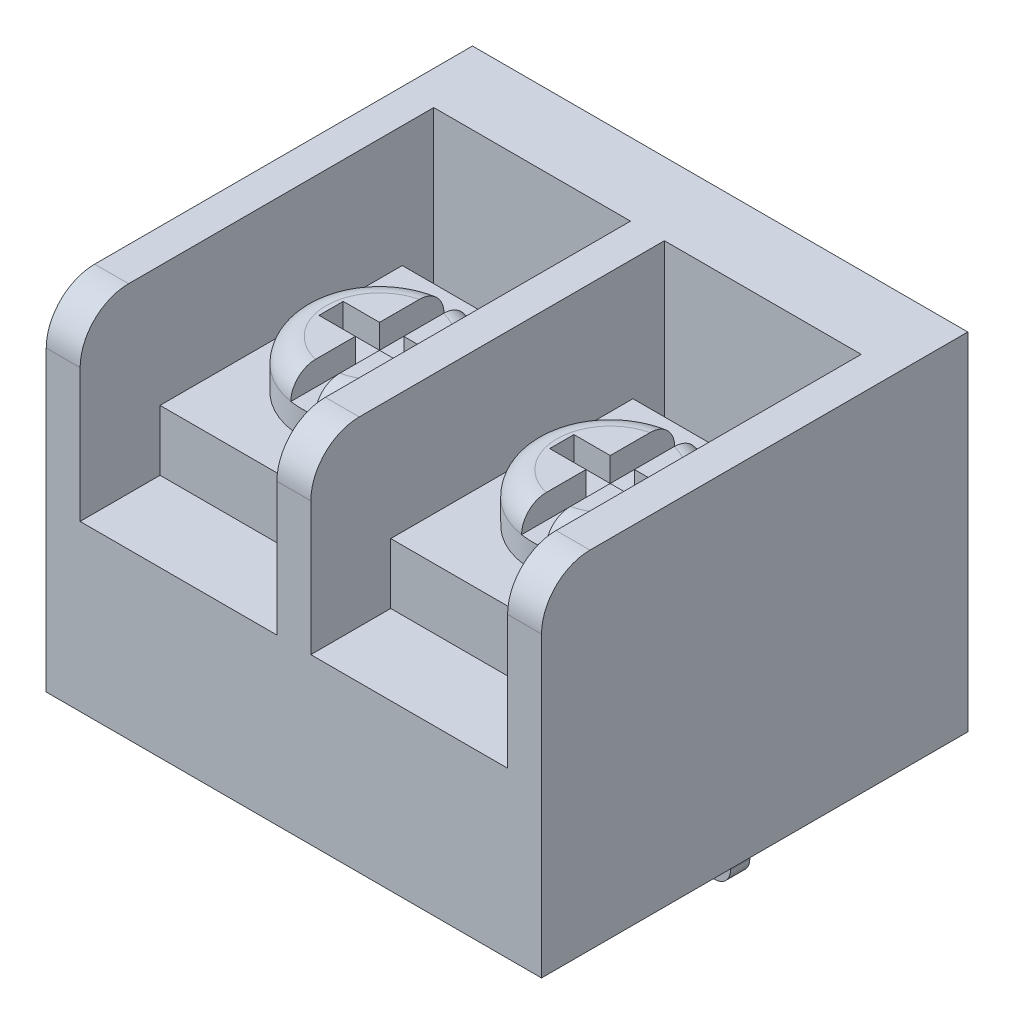
from build123d import *

# Parameters (mm, degrees)
SKETCH1_W             = 20.45
SKETCH1_H             = 17.6
BOSS_EXTRUDE1_DEPTH   = 14.3
FILLET1_R             = 2
SKETCH2_W             = 8.125
SKETCH2_H             = 14.6
CUT_EXTRUDE1_DEPTH    = 7.5
SKETCH3_W             = 1.35
SKETCH3_H             = 0.8
BOSS_EXTRUDE2_DEPTH   = 5.5
BOSS_EXTRUDE2_2_DEPTH = 5.5
FILLET3_R             = 0.65
FILLET4_R             = 0.65
SKETCH4_W             = 8.125
SKETCH4_H             = 10
BOSS_EXTRUDE3_DEPTH   = 2.5
BOSS_EXTRUDE3_2_DEPTH = 2.5
SKETCH5_R             = 3.2
BOSS_EXTRUDE4_DEPTH   = 2
CUT_EXTRUDE2_DEPTH    = 1
FILLET5_R             = 1
FILLET6_R             = 1


with BuildPart() as part:
    # Sketch1 → Boss-Extrude1 (new body)
    with BuildSketch(Plane(origin=(0, 0, 0), x_dir=(1, 0, 0), z_dir=(0, 1, 0))):
        Rectangle(SKETCH1_W, SKETCH1_H)
    extrude(amount=BOSS_EXTRUDE1_DEPTH)

    # Fillet1
    fillet1_edges = [part.edges().sort_by_distance(p)[0] for p in [
        (0, 14.3, 8.8),
    ]]
    fillet(fillet1_edges, radius=FILLET1_R)

    # Sketch2 → Cut-Extrude1 (cut)
    with BuildSketch(Plane(origin=(0, 14.3, 0), x_dir=(1, 0, 0), z_dir=(0, 1, 0))):
        with Locations((-4.7625, -1.5)):
            Rectangle(SKETCH2_W, SKETCH2_H)
        with Locations((4.7625, -1.5)):
            Rectangle(SKETCH2_W, SKETCH2_H)
    extrude(amount=-CUT_EXTRUDE1_DEPTH, mode=Mode.SUBTRACT)


with BuildPart() as body_2:
    # Sketch3 → Boss-Extrude2 (new body)
    with BuildSketch(Plane.XZ):
        with Locations((-4.75, -4.2)):
            Rectangle(SKETCH3_W, SKETCH3_H)
    extrude(amount=BOSS_EXTRUDE2_DEPTH)

    # Fillet4
    fillet4_edges = [body_2.edges().sort_by_distance(p)[0] for p in [
        (-4.075, -5.5, -4.2),
        (-5.425, -5.5, -4.2),
    ]]
    fillet(fillet4_edges, radius=FILLET4_R)


with BuildPart() as body_3:
    # Sketch3 → Boss-Extrude2 2 (new body)
    with BuildSketch(Plane.XZ):
        with Locations((4.75, -4.2)):
            Rectangle(SKETCH3_W, SKETCH3_H)
    extrude(amount=BOSS_EXTRUDE2_2_DEPTH)

    # Fillet3
    fillet3_edges = [body_3.edges().sort_by_distance(p)[0] for p in [
        (5.425, -5.5, -4.2),
        (4.075, -5.5, -4.2),
    ]]
    fillet(fillet3_edges, radius=FILLET3_R)


with BuildPart() as body_4:
    # Sketch4 → Boss-Extrude3 (new body)
    with BuildSketch(Plane(origin=(0, 6.8, 0), x_dir=(1, 0, 0), z_dir=(0, 1, 0))):
        with Locations((-4.7625, -0.5)):
            Rectangle(SKETCH4_W, SKETCH4_H)
    extrude(amount=BOSS_EXTRUDE3_DEPTH)



with BuildPart() as body_5:
    # Sketch4 → Boss-Extrude3 2 (new body)
    with BuildSketch(Plane(origin=(0, 6.8, 0), x_dir=(1, 0, 0), z_dir=(0, 1, 0))):
        with Locations((4.7625, -0.5)):
            Rectangle(SKETCH4_W, SKETCH4_H)
    extrude(amount=BOSS_EXTRUDE3_2_DEPTH)


with BuildPart() as body_4_1:
    add(body_4.part)

    add(body_5.part)  # Boss-Extrude4 merges body 5
    # Sketch5 → Boss-Extrude4 (add)
    with BuildSketch(Plane(origin=(0, 9.3, 0), x_dir=(1, 0, 0), z_dir=(0, 1, 0))):
        with Locations((-4.7625, -0.5)):
            Circle(SKETCH5_R)
        with Locations((4.7625, -0.5)):
            Circle(SKETCH5_R)
    extrude(amount=BOSS_EXTRUDE4_DEPTH)

    # Sketch6 → Cut-Extrude2 (cut)
    with BuildSketch(Plane(origin=(0, 11.3, 0), x_dir=(1, 0, 0), z_dir=(0, 1, 0))):
        Polygon((-5.2625, 2.7), (-5.2625, 0), (-6.7625, 0), (-6.7625, -1), (-5.2625, -1), (-5.2625, -3.7), (-4.2625, -3.7), (-4.2625, -1), (-2.7625, -1), (-2.7625, 0), (-4.2625, 0), (-4.2625, 2.7), align=None)
        Polygon((4.2625, 0), (4.2625, 2.7), (5.2625, 2.7), (5.2625, 0), (6.7625, 0), (6.7625, -1), (5.2625, -1), (5.2625, -3.7), (4.2625, -3.7), (4.2625, -1), (2.7625, -1), (2.7625, 0), align=None)
    extrude(amount=-CUT_EXTRUDE2_DEPTH, mode=Mode.SUBTRACT)

    # Fillet5
    fillet5_edges = [body_4_1.edges().sort_by_distance(p)[0] for p in [
        (-2.329394988, 11.3, -1.578460969),
        (-7.9625, 11.3, 0.5),
    ]]
    fillet(fillet5_edges, radius=FILLET5_R)

    # Fillet6
    fillet6_edges = [body_4_1.edges().sort_by_distance(p)[0] for p in [
        (7.195605012, 11.3, -1.578460969),
        (1.5625, 11.3, 0.5),
    ]]
    fillet(fillet6_edges, radius=FILLET6_R)


solid = Compound([part.part, body_2.part, body_3.part, body_4_1.part])
